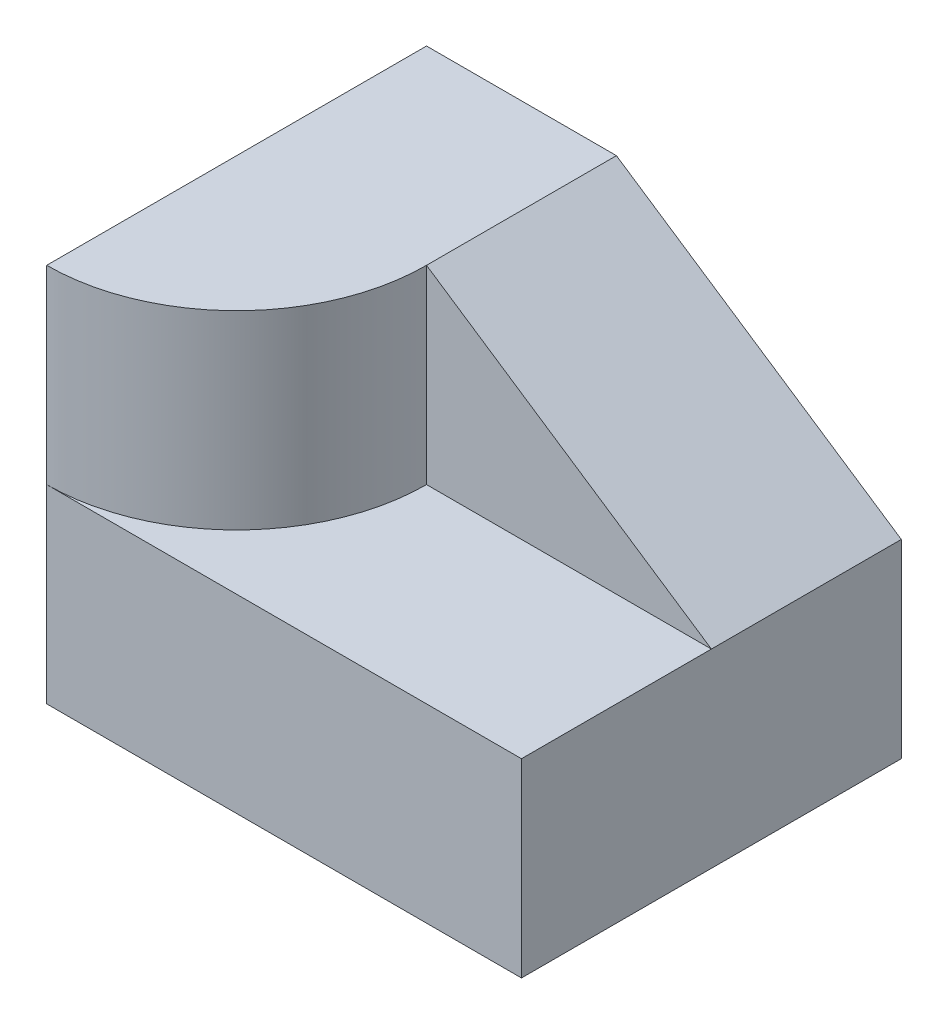
from build123d import *

# Parameters (mm, degrees)
SKETCH_1_W          = 25
SKETCH_1_H          = 20
EXTRUDE_1_DEPTH     = 10
EXTRUDE_2_DEPTH     = 20
CUT_EXTRUDE_1_DEPTH = 20


with BuildPart() as part:
    # 草圖1 → 填料-伸長1 (new body)
    with BuildSketch(Plane(origin=(0, 0, 0), x_dir=(1, 0, 0), z_dir=(0, 1, 0))):
        Rectangle(SKETCH_1_W, SKETCH_1_H)
    extrude(amount=EXTRUDE_1_DEPTH)

    # 草圖1<3> → 填料-伸長2 (add)
    with BuildSketch(Plane(origin=(0, 0, 0), x_dir=(1, 0, 0), z_dir=(0, 1, 0))):
        with BuildLine():
            Line((-12.5, 10), (-12.5, -10))
            ThreePointArc((-12.5, -10), (-5.428932188, -7.071067812), (-2.5, 0))
            Line((-2.5, 0), (12.5, 0))
            Line((12.5, 0), (12.5, 10))
            Line((12.5, 10), (-12.5, 10))
        make_face()
    extrude(amount=EXTRUDE_2_DEPTH)

    # 草圖2 → 除料-伸長1 (cut)
    with BuildSketch(Plane.XY):
        Polygon((-2.5, 20), (12.5, 10), (12.5, 20), align=None)
    extrude(amount=-CUT_EXTRUDE_1_DEPTH, mode=Mode.SUBTRACT)


solid = part.part
